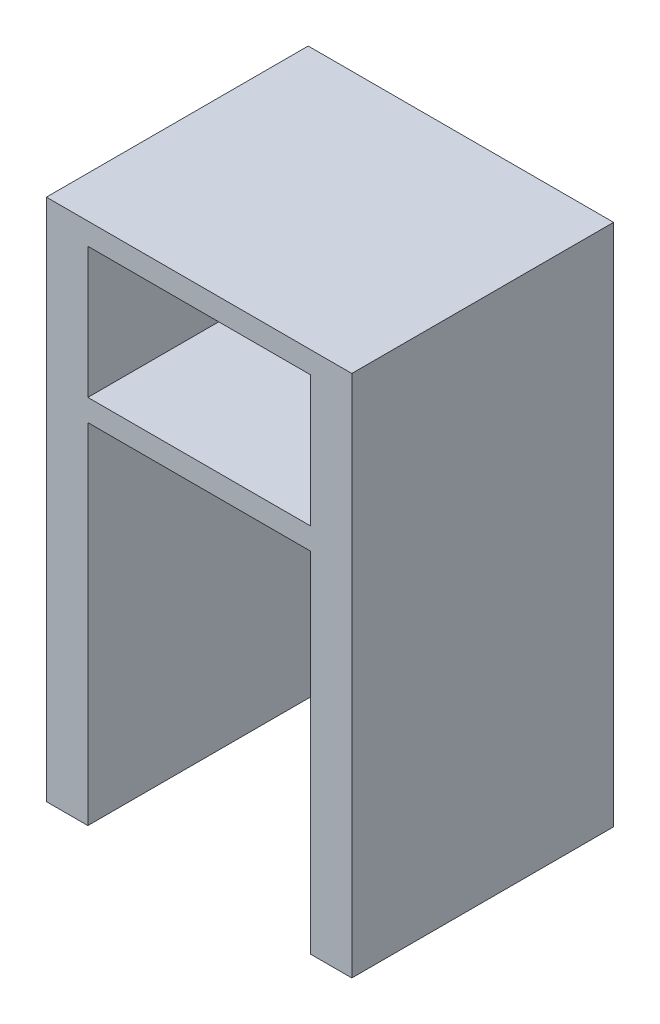
from build123d import *

# Parameters (mm, degrees)
SCHIZZO1_W                   = 140
SCHIZZO1_H                   = 240
ESTRUSIONE_ESTRUSIONE1_DEPTH = 120
SCHIZZO2_W                   = 102
SCHIZZO2_H                   = 160
SCHIZZO2_H_2                 = 60
TAGLIO_ESTRUSIONE1_DEPTH     = 120


with BuildPart() as part:
    # Schizzo1 → Estrusione-Estrusione1 (new body)
    with BuildSketch(Plane.XY):
        Rectangle(SCHIZZO1_W, SCHIZZO1_H)
    extrude(amount=ESTRUSIONE_ESTRUSIONE1_DEPTH)

    # Schizzo2 → Taglio-Estrusione1 (cut)
    with BuildSketch(Plane.XY.offset(120)):
        with Locations((0, -40)):
            Rectangle(SCHIZZO2_W, SCHIZZO2_H)
        with Locations((0, 80)):
            Rectangle(SCHIZZO2_W, SCHIZZO2_H_2)
    extrude(amount=-TAGLIO_ESTRUSIONE1_DEPTH, mode=Mode.SUBTRACT)


solid = part.part
